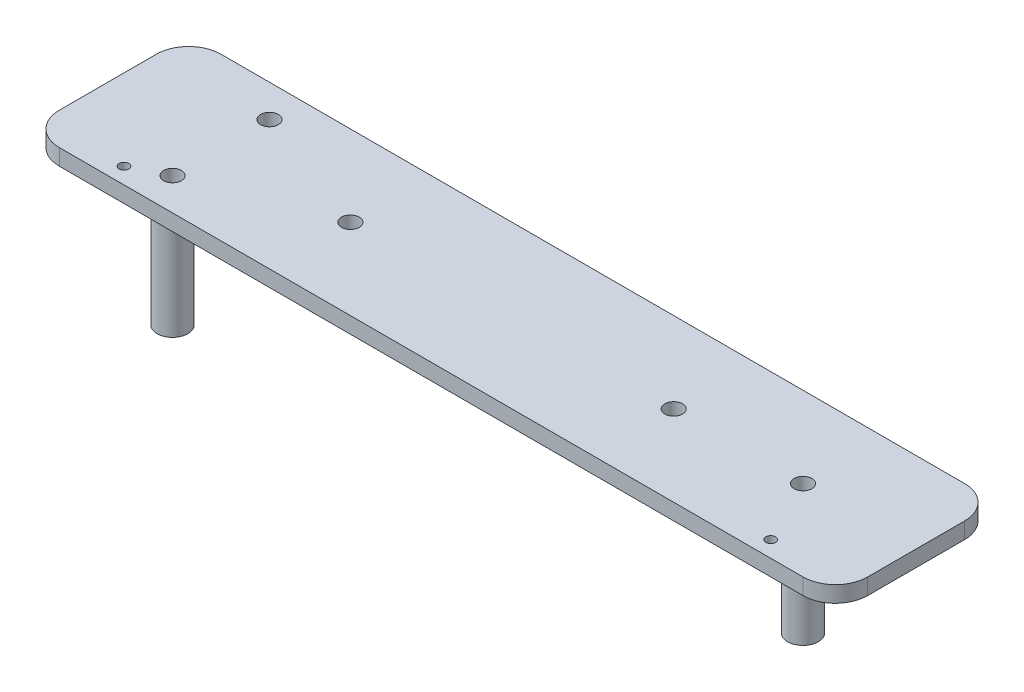
from build123d import *

# Parameters (mm, degrees)
SKETCH1_R           = 2.75
SKETCH1_R_2         = 1.5
BOSS_EXTRUDE1_DEPTH = 5
SKETCH2_R           = 4.75
SKETCH2_R_2         = 2.75
BOSS_EXTRUDE2_DEPTH = 35


with BuildPart() as part:
    # Sketch1 → Boss-Extrude1 (new body)
    with BuildSketch(Plane(origin=(0, 0, 0), x_dir=(1, 0, 0), z_dir=(0, 1, 0))):
        with BuildLine():
            Line((-115, 25), (115, 25))
            ThreePointArc((115, 25), (122.071067812, 22.071067812), (125, 15))
            Line((125, 15), (125, -15))
            ThreePointArc((125, -15), (122.071067812, -22.071067812), (115, -25))
            Line((115, -25), (-115, -25))
            ThreePointArc((-115, -25), (-122.071067812, -22.071067812), (-125, -15))
            Line((-125, -15), (-125, 15))
            ThreePointArc((-125, 15), (-122.071067812, 22.071067812), (-115, 25))
        make_face()
        with Locations((90, 0)):
            Circle(SKETCH1_R, mode=Mode.SUBTRACT)
        with Locations((-90, 15)):
            Circle(SKETCH1_R, mode=Mode.SUBTRACT)
        with Locations((-50, 0)):
            Circle(SKETCH1_R, mode=Mode.SUBTRACT)
        with Locations((50, 0)):
            Circle(SKETCH1_R, mode=Mode.SUBTRACT)
        with Locations((-90, -15)):
            Circle(SKETCH1_R, mode=Mode.SUBTRACT)
        with Locations((-100, -20)):
            Circle(SKETCH1_R_2, mode=Mode.SUBTRACT)
        with Locations((100, -20)):
            Circle(SKETCH1_R_2, mode=Mode.SUBTRACT)
    extrude(amount=BOSS_EXTRUDE1_DEPTH)

    # Sketch2 → Boss-Extrude2 (add)
    with BuildSketch(Plane(origin=(0, 0, 0), x_dir=(-1, 0, 0), z_dir=(0, -1, 0))):
        with Locations((90, -15)):
            Circle(SKETCH2_R)
        with Locations((90, -15)):
            Circle(SKETCH2_R_2, mode=Mode.SUBTRACT)
        with Locations((90, 15)):
            Circle(SKETCH2_R)
        with Locations((90, 15)):
            Circle(SKETCH2_R_2, mode=Mode.SUBTRACT)
        with Locations((-90, 0)):
            Circle(SKETCH2_R)
        with Locations((-90, 0)):
            Circle(SKETCH2_R_2, mode=Mode.SUBTRACT)
    extrude(amount=BOSS_EXTRUDE2_DEPTH)


solid = part.part
